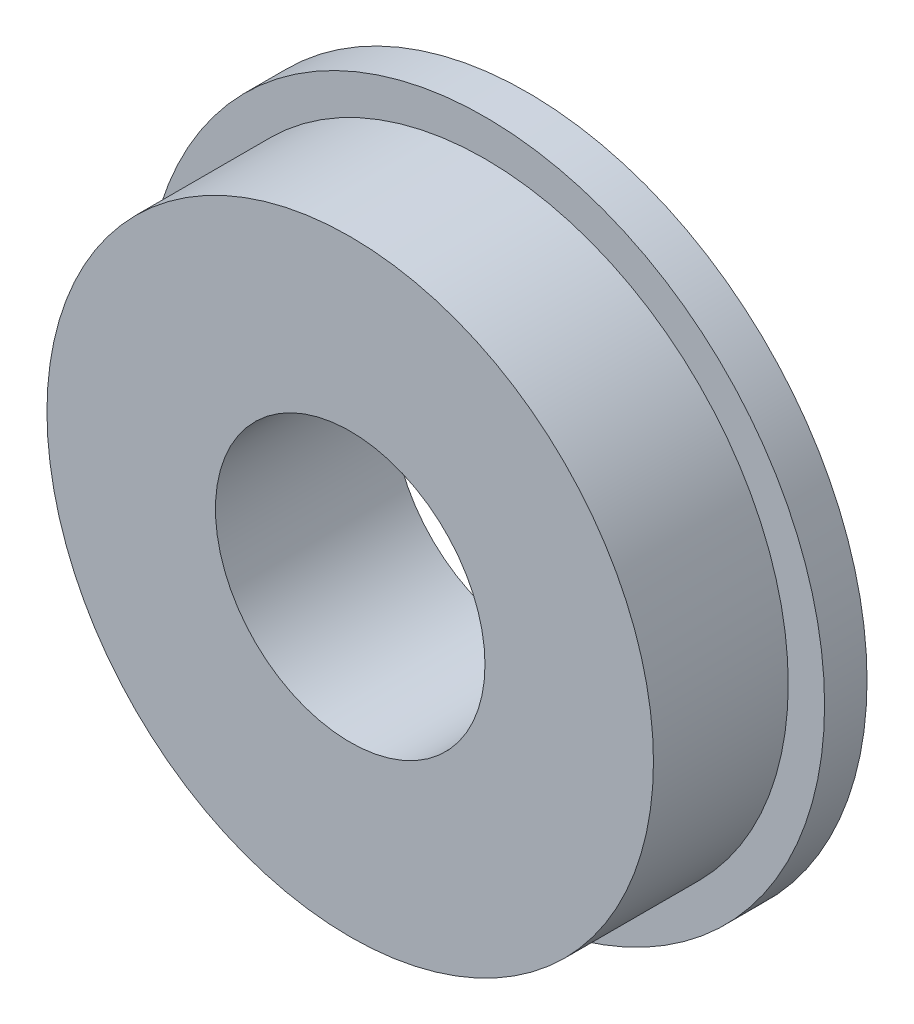
from build123d import *

# Parameters (mm, degrees)
SKETCH1_R           = 16
BOSS_EXTRUDE1_DEPTH = 2
SKETCH2_R           = 14.2875
BOSS_EXTRUDE2_DEPTH = 6.35
SKETCH3_R           = 6.35
CUT_EXTRUDE1_DEPTH  = 8.35


with BuildPart() as part:
    # Sketch1 → Boss-Extrude1 (new body)
    with BuildSketch(Plane.XY):
        Circle(SKETCH1_R)
    extrude(amount=BOSS_EXTRUDE1_DEPTH)

    # Sketch2 → Boss-Extrude2 (add)
    with BuildSketch(Plane.XY.offset(2)):
        Circle(SKETCH2_R)
    extrude(amount=BOSS_EXTRUDE2_DEPTH)

    # Sketch3 → Cut-Extrude1 (cut)
    with BuildSketch(Plane.XY.offset(8.35)):
        Circle(SKETCH3_R)
    extrude(amount=-CUT_EXTRUDE1_DEPTH, mode=Mode.SUBTRACT)


solid = part.part
